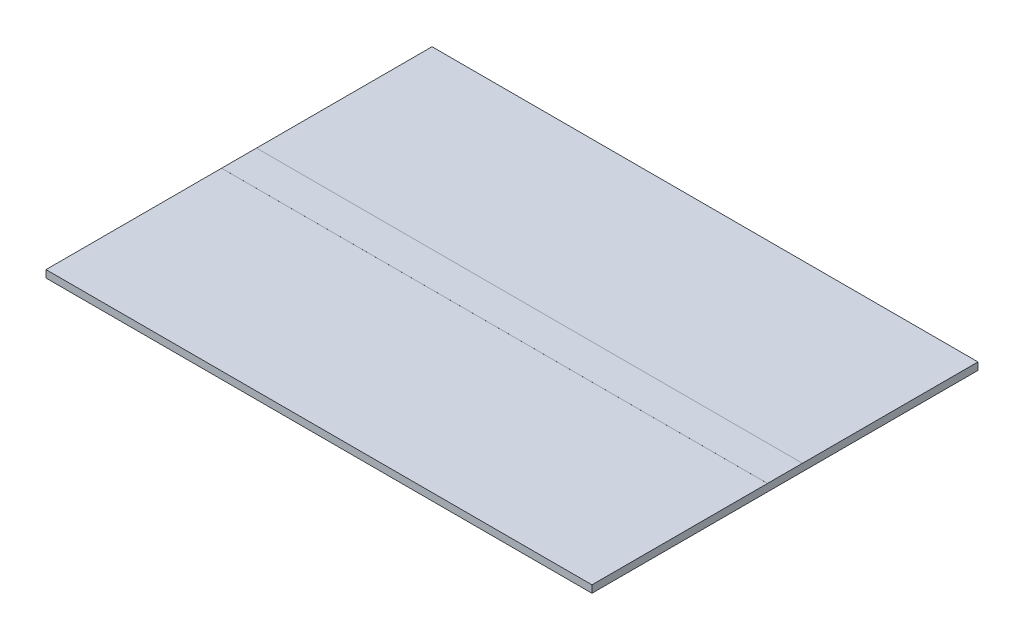
from build123d import *

# Parameters (mm, degrees)
SKETCH1_W           = 297
SKETCH1_H           = 210
BOSS_EXTRUDE1_DEPTH = 4
SKETCH2_W           = 297
SKETCH2_H           = 19
BOSS_EXTRUDE2_DEPTH = 0.01


with BuildPart() as part:
    # Sketch1 → Boss-Extrude1 (new body)
    with BuildSketch(Plane(origin=(0, 0, 0), x_dir=(1, 0, 0), z_dir=(0, 1, 0))):
        with Locations((21.134130982, -33.742443325)):
            Rectangle(SKETCH1_W, SKETCH1_H)
    extrude(amount=BOSS_EXTRUDE1_DEPTH)

    # Sketch2 → Boss-Extrude2 (add)
    with BuildSketch(Plane(origin=(0, 4, 0), x_dir=(1, 0, 0), z_dir=(0, 1, 0))):
        with Locations((21.134130982, -33.742443325)):
            Rectangle(SKETCH2_W, SKETCH2_H)
    extrude(amount=BOSS_EXTRUDE2_DEPTH)


solid = part.part
